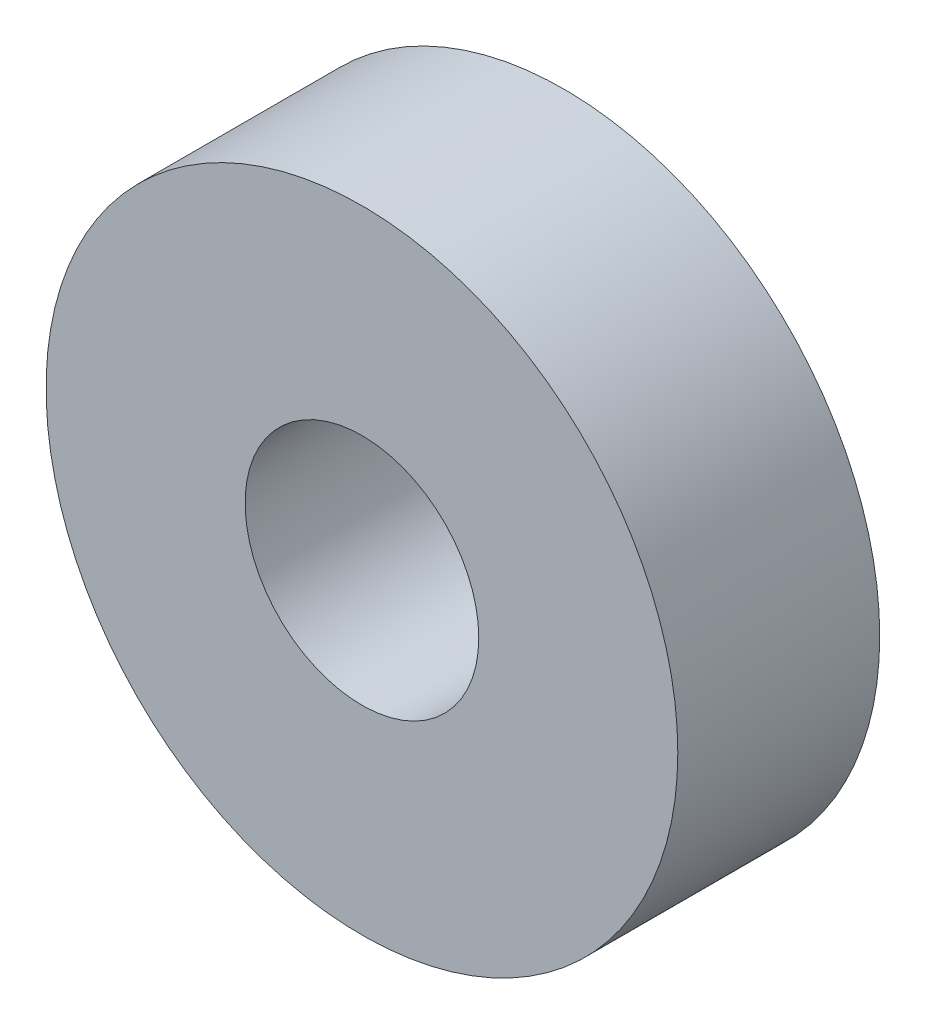
from build123d import *

# Parameters (mm, degrees)
SKETCH_1_R      = 10.95
SKETCH_1_R_2    = 4.05
EXTRUDE_1_DEPTH = 7


with BuildPart() as part:
    # Эскиз1 → Бобышка-Вытянуть1 (new body)
    with BuildSketch(Plane.XY):
        Circle(SKETCH_1_R)
        Circle(SKETCH_1_R_2, mode=Mode.SUBTRACT)
    extrude(amount=EXTRUDE_1_DEPTH)


solid = part.part
